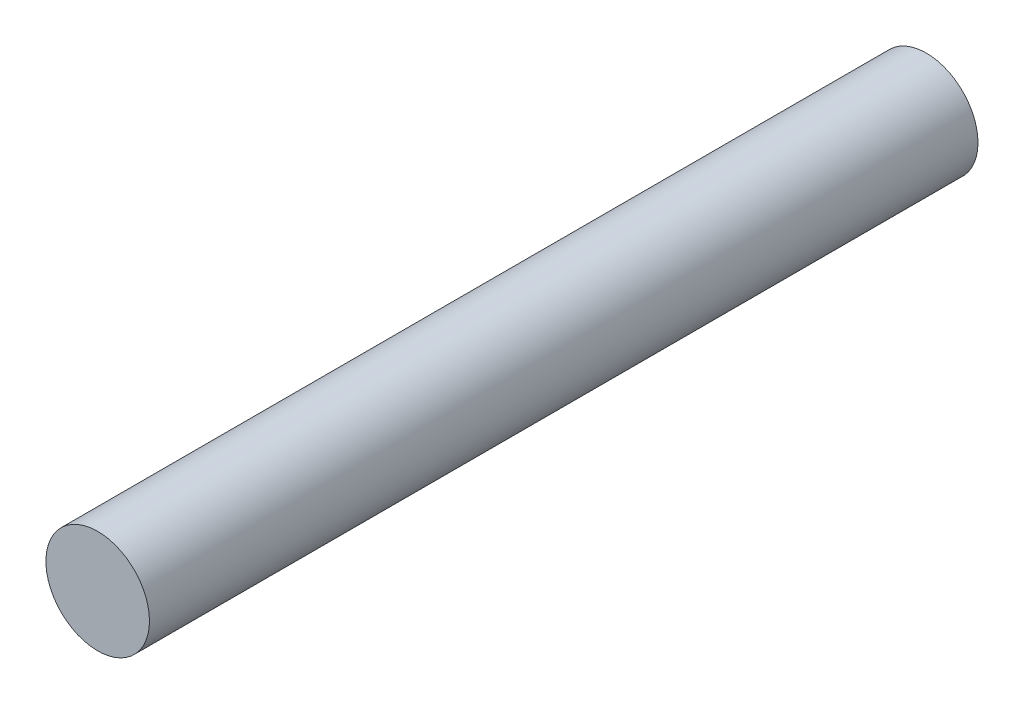
from build123d import *

# Parameters (mm, degrees)
SKETCH1_R           = 4.7625
BOSS_EXTRUDE1_DEPTH = 76.2


with BuildPart() as part:
    # Sketch1 → Boss-Extrude1 (new body)
    with BuildSketch(Plane.XY):
        Circle(SKETCH1_R)
    extrude(amount=-BOSS_EXTRUDE1_DEPTH)


solid = part.part
